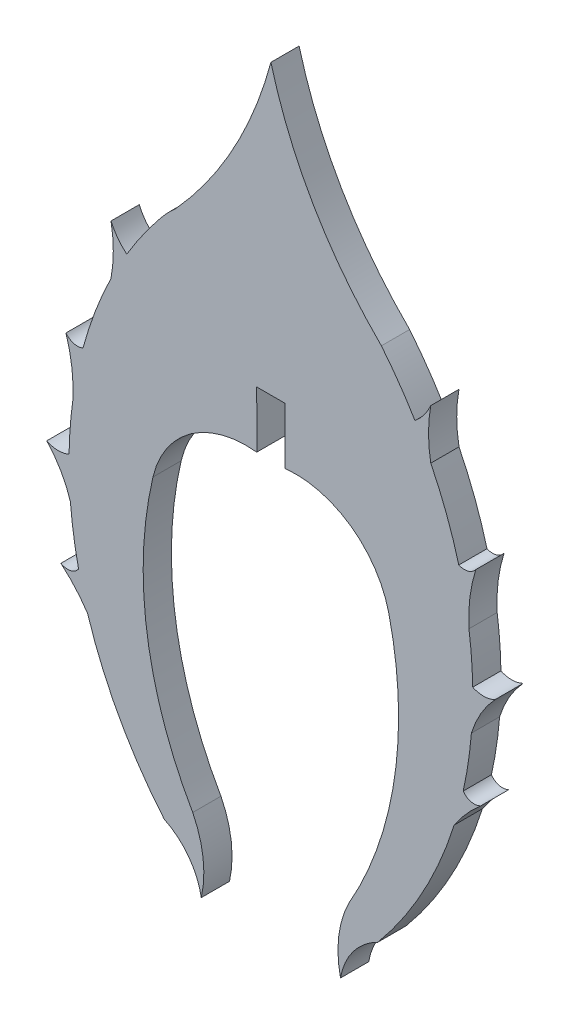
from build123d import *

# Parameters (mm, degrees)
BOSS_EXTRUDE1_DEPTH = 1.524


with BuildPart() as part:
    # Sketch1 → Boss-Extrude1 (new body)
    with BuildSketch(Plane.XY):
        with BuildLine():
            Line((-0.760070899, 7.460977954), (0.767897128, 7.459984541))
            Line((0.767897128, 7.459984541), (0.765910301, 4.411002891))
            ThreePointArc((0.765910301, 4.411002891), (4.32194984, 3.493667889), (6.372371333, 0.446916765))
            ThreePointArc((6.372371333, 0.446916765), (6.688594723, -7.066471539), (4.226511646, -14.172043153))
            ThreePointArc((4.226511646, -14.172043153), (3.666960455, -16.006802716), (3.76324428, -17.922571391))
            ThreePointArc((3.76324428, -17.922571391), (4.445796565, -16.344729964), (5.770776644, -15.249335522))
            ThreePointArc((5.770776644, -15.249335522), (8.209412547, -11.678891072), (9.901915798, -7.700141093))
            ThreePointArc((9.901915798, -7.700141093), (10.56591512, -6.836092284), (11.345730748, -6.07493328))
            ThreePointArc((11.345730748, -6.07493328), (10.826887202, -6.157946188), (10.391178227, -5.864267011))
            ThreePointArc((10.391178227, -5.864267011), (10.661740328, -4.406185462), (10.833367262, -2.933178384))
            ThreePointArc((10.833367262, -2.933178384), (11.345730748, -1.758358454), (12.109295167, -0.728947171))
            ThreePointArc((12.109295167, -0.728947171), (11.509245819, -0.877984338), (10.904429696, -0.749653693))
            ThreePointArc((10.904429696, -0.749653693), (10.842155911, 0.568514134), (10.700889839, 1.880569141))
            ThreePointArc((10.700889839, 1.880569141), (10.750460558, 3.375199082), (11.072247287, 4.835619986))
            ThreePointArc((11.072247287, 4.835619986), (10.654347315, 4.554276024), (10.151679138, 4.587735186))
            ThreePointArc((10.151679138, 4.587735186), (9.493497129, 6.629427415), (8.639426453, 8.597236857))
            ThreePointArc((8.639426453, 8.597236857), (8.516035962, 9.943618933), (8.639426453, 11.29000101))
            ThreePointArc((8.639426453, 11.29000101), (8.278476637, 10.67654613), (7.787243967, 10.161471258))
            ThreePointArc((7.787243967, 10.161471258), (6.925869801, 11.489539462), (5.971147131, 12.752169745))
            ThreePointArc((5.971147131, 12.752169745), (2.303316115, 17.492889529), (0.004783201, 23.028605823))
            ThreePointArc((0.004783201, 23.028605823), (-1.992221452, 18.030222496), (-5.110354293, 13.642841609))
            ThreePointArc((-5.110354293, 13.642841609), (-5.554708445, 13.214619989), (-5.963320902, 12.752169745))
            ThreePointArc((-5.963320902, 12.752169745), (-6.918043572, 11.489539462), (-7.779417738, 10.161471258))
            ThreePointArc((-7.779417738, 10.161471258), (-8.270650408, 10.67654613), (-8.631600224, 11.29000101))
            ThreePointArc((-8.631600224, 11.29000101), (-8.508209733, 9.943618933), (-8.631600224, 8.597236857))
            ThreePointArc((-8.631600224, 8.597236857), (-9.4856709, 6.629427415), (-10.14385291, 4.587735186))
            ThreePointArc((-10.14385291, 4.587735186), (-10.646521087, 4.554276024), (-11.064421059, 4.835619986))
            ThreePointArc((-11.064421059, 4.835619986), (-10.742634329, 3.375199082), (-10.69306361, 1.880569141))
            ThreePointArc((-10.69306361, 1.880569141), (-10.834329682, 0.568514134), (-10.896603467, -0.749653693))
            ThreePointArc((-10.896603467, -0.749653693), (-11.50141959, -0.877984338), (-12.101468938, -0.728947171))
            ThreePointArc((-12.101468938, -0.728947171), (-11.33790452, -1.758358454), (-10.825541034, -2.933178384))
            ThreePointArc((-10.825541034, -2.933178384), (-10.653914099, -4.406185462), (-10.383351998, -5.864267011))
            ThreePointArc((-10.383351998, -5.864267011), (-10.819060973, -6.157946188), (-11.33790452, -6.07493328))
            ThreePointArc((-11.33790452, -6.07493328), (-10.558088891, -6.836092284), (-9.894089569, -7.700141093))
            ThreePointArc((-9.894089569, -7.700141093), (-8.201586318, -11.678891072), (-5.762950415, -15.249335522))
            ThreePointArc((-5.762950415, -15.249335522), (-4.437970336, -16.344729964), (-3.755418051, -17.922571391))
            ThreePointArc((-3.755418051, -17.922571391), (-3.659134226, -16.006802716), (-4.218685417, -14.172043153))
            ThreePointArc((-4.218685417, -14.172043153), (-6.680768494, -7.066471539), (-6.364545104, 0.446916765))
            ThreePointArc((-6.364545104, 0.446916765), (-4.314549444, 3.493366768), (-0.759120805, 4.411117837))
            Line((-0.759120805, 4.411117837), (-0.760070899, 7.460977954))
        make_face()
    extrude(amount=BOSS_EXTRUDE1_DEPTH)


solid = part.part
